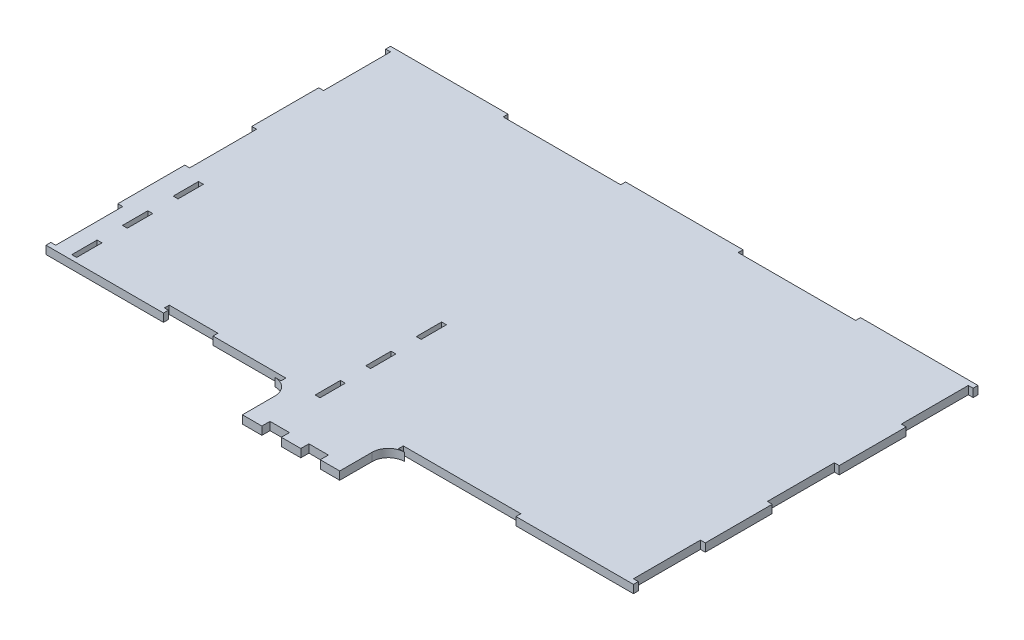
from build123d import *

# Parameters (mm, degrees)
SKETCH1_W           = 3
SKETCH1_H           = 15.635202888
SKETCH1_H_2         = 15.6
SKETCH1_H_3         = 15.635202889
BOSS_EXTRUDE1_DEPTH = 5


with BuildPart() as part:
    # Sketch1 → Boss-Extrude1 (new body)
    with BuildSketch(Plane(origin=(0, 0, 0), x_dir=(1, 0, 0), z_dir=(0, 1, 0))):
        with BuildLine():
            Line((-30.000015974, -136.250310986), (-18.000015974, -136.250310986))
            Line((-18.000015974, -136.250310986), (-18.000015974, -131.250310986))
            Line((-18.000015974, -131.250310986), (-6.000015974, -131.250310986))
            Line((-6.000015974, -131.250310986), (-6.000015974, -136.250310986))
            Line((-6.000015974, -136.250310986), (5.999984026, -136.250310986))
            Line((5.999984026, -136.250310986), (5.999984026, -131.250310986))
            Line((5.999984026, -131.250310986), (17.999984026, -131.250310986))
            Line((17.999984026, -131.250310986), (17.999984026, -136.250310986))
            Line((17.999984026, -136.250310986), (30.000006721, -136.250310986))
            Line((30.000006721, -136.250310986), (30.000006721, -116.24999063))
            ThreePointArc((30.000006721, -116.24999063), (32.92893891, -109.178922818), (40.000006721, -106.24999063))
            Line((40.000006721, -106.24999063), (36.229984025, -106.24999063))
            Line((36.229984025, -106.24999063), (36.229984025, -103.249670275))
            Line((36.229984025, -103.249670275), (108.689984025, -103.249670275))
            Line((108.689984025, -103.249670275), (108.689984025, -106.24999063))
            Line((108.689984025, -106.24999063), (181.149984025, -106.24999063))
            Line((181.149984025, -106.24999063), (181.149984025, -103.24999063))
            Line((181.149984025, -103.24999063), (178.149984476, -103.24999063))
            Line((178.149984476, -103.24999063), (178.149984476, -61.94999063))
            Line((178.149984476, -61.94999063), (181.149984025, -61.94999063))
            Line((181.149984025, -61.94999063), (181.149984025, -20.64999063))
            Line((181.149984025, -20.64999063), (178.149984927, -20.64999063))
            Line((178.149984927, -20.64999063), (178.149984927, 20.65000937))
            Line((178.149984927, 20.65000937), (181.149984025, 20.65000937))
            Line((181.149984025, 20.65000937), (181.149984025, 61.95000937))
            Line((181.149984025, 61.95000937), (178.149984927, 61.95000937))
            Line((178.149984927, 61.95000937), (178.149984927, 103.25000937))
            Line((178.149984927, 103.25000937), (181.149984025, 103.25000937))
            Line((181.149984025, 103.25000937), (181.150047924, 106.25000937))
            Line((181.150047924, 106.25000937), (108.689984025, 106.25000937))
            Line((108.689984025, 106.25000937), (108.689984025, 103.249689014))
            Line((108.689984025, 103.249689014), (36.229984025, 103.249689014))
            Line((36.229984025, 103.249689014), (36.229984025, 106.25000937))
            Line((36.229984025, 106.25000937), (-36.230015974, 106.25000937))
            Line((-36.230015974, 106.25000937), (-36.230015974, 103.249689014))
            Line((-36.230015974, 103.249689014), (-108.690015974, 103.249689014))
            Line((-108.690015974, 103.249689014), (-108.690015974, 106.25000937))
            Line((-108.690015974, 106.25000937), (-181.150015974, 106.25000937))
            Line((-181.150015974, 106.25000937), (-181.150015974, 103.25000937))
            Line((-181.150015974, 103.25000937), (-178.150016876, 103.25000937))
            Line((-178.150016876, 103.25000937), (-178.150016876, 61.95000937))
            Line((-178.150016876, 61.95000937), (-181.150015974, 61.95000937))
            Line((-181.150015974, 61.95000937), (-181.150015974, 20.65000937))
            Line((-181.150015974, 20.65000937), (-178.150016876, 20.65000937))
            Line((-178.150016876, 20.65000937), (-178.150016876, -20.64999063))
            Line((-178.150016876, -20.64999063), (-181.150015974, -20.64999063))
            Line((-181.150015974, -20.64999063), (-181.150015974, -61.94999063))
            Line((-181.150015974, -61.94999063), (-178.150016425, -61.94999063))
            Line((-178.150016425, -61.94999063), (-178.150016425, -103.24999063))
            Line((-178.150016425, -103.24999063), (-181.150015974, -103.24999063))
            Line((-181.150015974, -103.24999063), (-181.150015974, -106.24999063))
            Line((-181.150015974, -106.24999063), (-108.690015974, -106.24999063))
            Line((-108.690015974, -106.24999063), (-108.690015974, -103.24999063))
            Line((-108.690015974, -103.24999063), (-111.150015974, -103.24999063))
            Line((-111.150015974, -103.24999063), (-111.150015974, -100.24999063))
            Line((-111.150015974, -100.24999063), (-81.150015974, -100.24999063))
            Line((-81.150015974, -100.24999063), (-81.150015974, -103.249670275))
            Line((-81.150015974, -103.249670275), (-36.230015974, -103.249670275))
            Line((-36.230015974, -103.249670275), (-36.230015974, -106.24999063))
            Line((-36.230015974, -106.24999063), (-40.000015974, -106.24999063))
            ThreePointArc((-40.000015974, -106.24999063), (-32.928948162, -109.178922818), (-30.000015974, -116.24999063))
            Line((-30.000015974, -116.24999063), (-30.000015974, -136.250310986))
        make_face()
        with Locations((-166.650000226, -95.537975278)):
            Rectangle(SKETCH1_W, SKETCH1_H, mode=Mode.SUBTRACT)
        with Locations((-16.650016425, -95.449968057)):
            Rectangle(SKETCH1_W, SKETCH1_H_2, mode=Mode.SUBTRACT)
        with Locations((-166.650000226, -32.997163725)):
            Rectangle(SKETCH1_W, SKETCH1_H, mode=Mode.SUBTRACT)
        with Locations((-16.650016425, -33.049968057)):
            Rectangle(SKETCH1_W, SKETCH1_H_2, mode=Mode.SUBTRACT)
        with Locations((-166.650000226, -64.267569502)):
            Rectangle(SKETCH1_W, SKETCH1_H_3, mode=Mode.SUBTRACT)
        with Locations((-16.650016425, -64.249968057)):
            Rectangle(SKETCH1_W, SKETCH1_H_2, mode=Mode.SUBTRACT)
    extrude(amount=BOSS_EXTRUDE1_DEPTH)


solid = part.part
